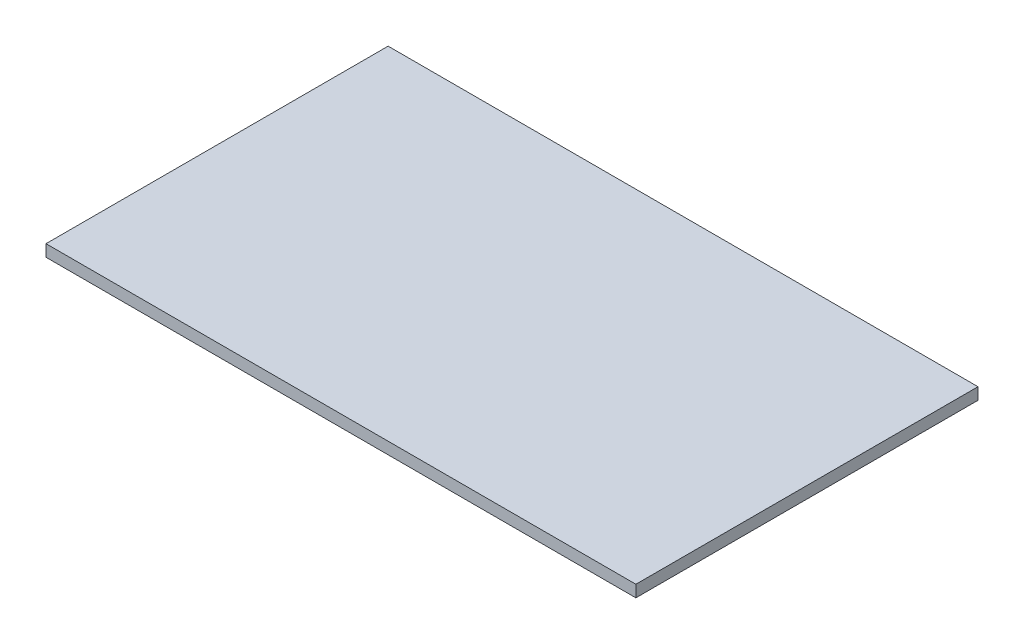
from build123d import *

# Parameters (mm, degrees)
SKETCH1_W           = 500
SKETCH1_H           = 290
BOSS_EXTRUDE1_DEPTH = 10


with BuildPart() as part:
    # Sketch1 → Boss-Extrude1 (new body)
    with BuildSketch(Plane(origin=(0, 0, 0), x_dir=(1, 0, 0), z_dir=(0, 1, 0))):
        Rectangle(SKETCH1_W, SKETCH1_H)
    extrude(amount=BOSS_EXTRUDE1_DEPTH)


solid = part.part
